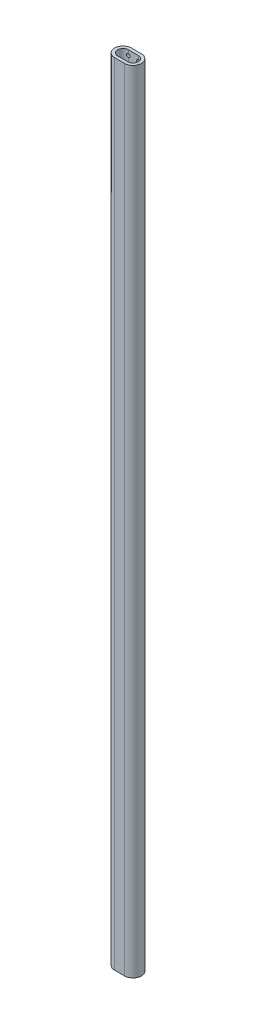
from build123d import *

# Parameters (mm, degrees)
BOSS_EXTRUDE1_DEPTH = 2997.2
SKETCH2_R           = 6.35
CUT_EXTRUDE1_DEPTH  = 25.4


with BuildPart() as part:
    # Sketch1 → Boss-Extrude1 (new body)
    with BuildSketch(Plane(origin=(0, 0, 0), x_dir=(1, 0, 0), z_dir=(0, 1, 0))):
        with BuildLine():
            Line((0, 31.75), (38.1, 31.75))
            ThreePointArc((38.1, 31.75), (69.85, 0), (38.1, -31.75))
            Line((38.1, -31.75), (0, -31.75))
            ThreePointArc((0, -31.75), (-31.75, 0), (0, 31.75))
        make_face()
        with BuildLine():
            Line((0, 20.304779167), (38.1, 20.304779167))
            ThreePointArc((38.1, 20.304779167), (58.404779167, 0), (38.1, -20.304779167))
            Line((38.1, -20.304779167), (0, -20.304779167))
            ThreePointArc((0, -20.304779167), (-20.304779167, 0), (0, 20.304779167))
        make_face(mode=Mode.SUBTRACT)
    extrude(amount=BOSS_EXTRUDE1_DEPTH)

    # Sketch2 → Cut-Extrude1 (cut)
    with BuildSketch(Plane(origin=(0, 0, -31.75), x_dir=(-1, 0, 0), z_dir=(0, 0, -1))):
        with Locations((-38.1, 19.05)):
            Circle(SKETCH2_R)
        with Locations((0, 19.05)):
            Circle(SKETCH2_R)
        with Locations((-38.1, 2978.15)):
            Circle(SKETCH2_R)
        with Locations((0, 2978.15)):
            Circle(SKETCH2_R)
    extrude(amount=-CUT_EXTRUDE1_DEPTH, mode=Mode.SUBTRACT)


solid = part.part
